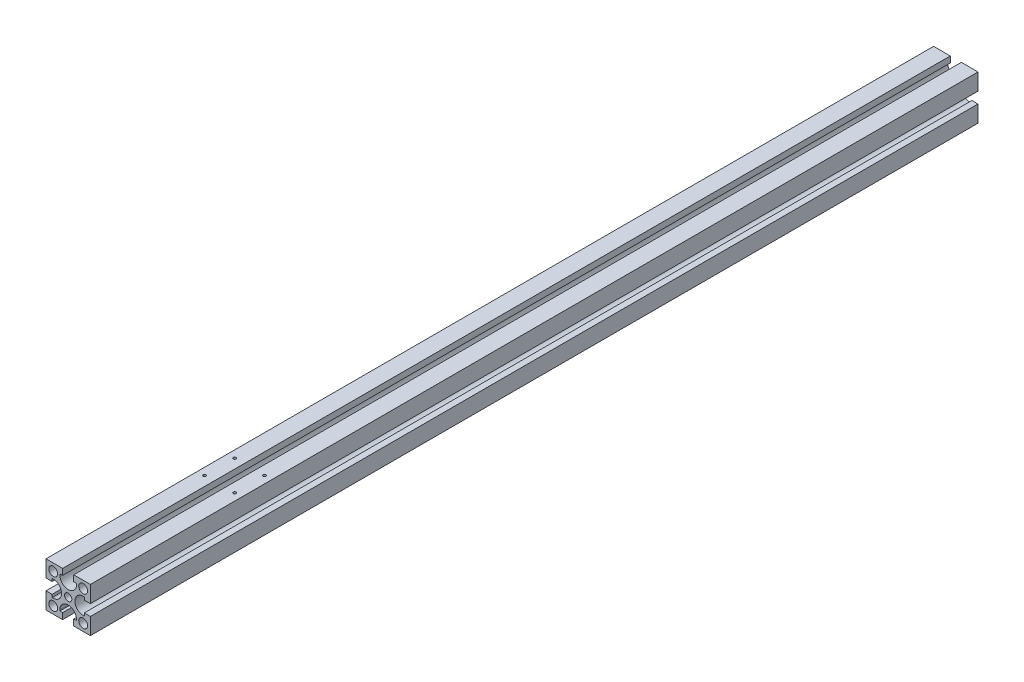
from build123d import *

# Parameters (mm, degrees)
SKETCH_1_W          = 40
SKETCH_1_H          = 40
EXTRUDE_1_DEPTH     = 800
SKETCH_2_R          = 3.25
SKETCH_2_R_2        = 4
CUT_EXTRUDE_1_DEPTH = 801
M3X0_5_1_D          = 2.5
M3X0_5_1_DEPTH      = 7.5
M3X0_5_1_TIP        = 0.751075774
M3X0_5_2_D          = 2.5
M3X0_5_2_DEPTH      = 7.5
M3X0_5_2_TIP        = 0.751075774


with BuildPart() as part:
    # 草圖1 → 伸長1 (new body)
    with BuildSketch(Plane.XY):
        Rectangle(SKETCH_1_W, SKETCH_1_H)
    extrude(amount=EXTRUDE_1_DEPTH)

    # 草圖2 → 除料-伸長1 (cut, through all)
    with BuildSketch(Plane(origin=(0, 0, 0), x_dir=(-1, 0, 0), z_dir=(0, 0, -1))):
        Circle(SKETCH_2_R)
        with Locations((-13.5, 13.5)):
            Circle(SKETCH_2_R_2)
        with Locations((13.5, 13.5)):
            Circle(SKETCH_2_R_2)
        with Locations((-13.5, -13.5)):
            Circle(SKETCH_2_R_2)
        with Locations((13.5, -13.5)):
            Circle(SKETCH_2_R_2)
        with BuildLine():
            Line((5, 14.5), (7.5, 14.5))
            Line((7.5, 14.5), (7.5, 13.5))
            ThreePointArc((7.5, 13.5), (0, 6), (-7.5, 13.5))
            Line((-7.5, 13.5), (-7.5, 14.5))
            Line((-7.5, 14.5), (-5, 14.5))
            Line((-5, 14.5), (-5, 20))
            Line((-5, 20), (5, 20))
            Line((5, 20), (5, 14.5))
        make_face()
        with BuildLine():
            Line((14.5, -5), (14.5, -7.5))
            Line((14.5, -7.5), (13.5, -7.5))
            ThreePointArc((13.5, -7.5), (6, 0), (13.5, 7.5))
            Line((13.5, 7.5), (14.5, 7.5))
            Line((14.5, 7.5), (14.5, 5))
            Line((14.5, 5), (20, 5))
            Line((20, 5), (20, -5))
            Line((20, -5), (14.5, -5))
        make_face()
        with BuildLine():
            Line((-5, -14.5), (-7.5, -14.5))
            Line((-7.5, -14.5), (-7.5, -13.5))
            ThreePointArc((-7.5, -13.5), (0, -6), (7.5, -13.5))
            Line((7.5, -13.5), (7.5, -14.5))
            Line((7.5, -14.5), (5, -14.5))
            Line((5, -14.5), (5, -20))
            Line((5, -20), (-5, -20))
            Line((-5, -20), (-5, -14.5))
        make_face()
        with BuildLine():
            Line((-14.5, 5), (-14.5, 7.5))
            Line((-14.5, 7.5), (-13.5, 7.5))
            ThreePointArc((-13.5, 7.5), (-6, 0), (-13.5, -7.5))
            Line((-13.5, -7.5), (-14.5, -7.5))
            Line((-14.5, -7.5), (-14.5, -5))
            Line((-14.5, -5), (-20, -5))
            Line((-20, -5), (-20, 5))
            Line((-20, 5), (-14.5, 5))
        make_face()
    extrude(amount=-CUT_EXTRUDE_1_DEPTH, mode=Mode.SUBTRACT)

    # M3x0.5 螺紋孔1
    with Locations(Plane(origin=(0, 20, 0), x_dir=(1, 0, 0), z_dir=(0, 1, 0))):
        with Locations((13.5, -663.5), (13.5, -636.5), (-13.5, -636.5), (-13.5, -663.5)):
            Hole(M3X0_5_1_D / 2, depth=M3X0_5_1_DEPTH)
            with Locations((0, 0, -(M3X0_5_1_DEPTH + M3X0_5_1_TIP / 2))):  # 118° drill point
                Cone(0, M3X0_5_1_D / 2, M3X0_5_1_TIP, mode=Mode.SUBTRACT)

    # M3x0.5 螺紋孔2
    with Locations(Plane(origin=(0, -20, 0), x_dir=(-1, 0, 0), z_dir=(0, -1, 0))):
        with Locations((13.5, -636.5), (13.5, -663.5), (-13.5, -663.5), (-13.5, -636.5)):
            Hole(M3X0_5_2_D / 2, depth=M3X0_5_2_DEPTH)
            with Locations((0, 0, -(M3X0_5_2_DEPTH + M3X0_5_2_TIP / 2))):  # 118° drill point
                Cone(0, M3X0_5_2_D / 2, M3X0_5_2_TIP, mode=Mode.SUBTRACT)


solid = part.part
